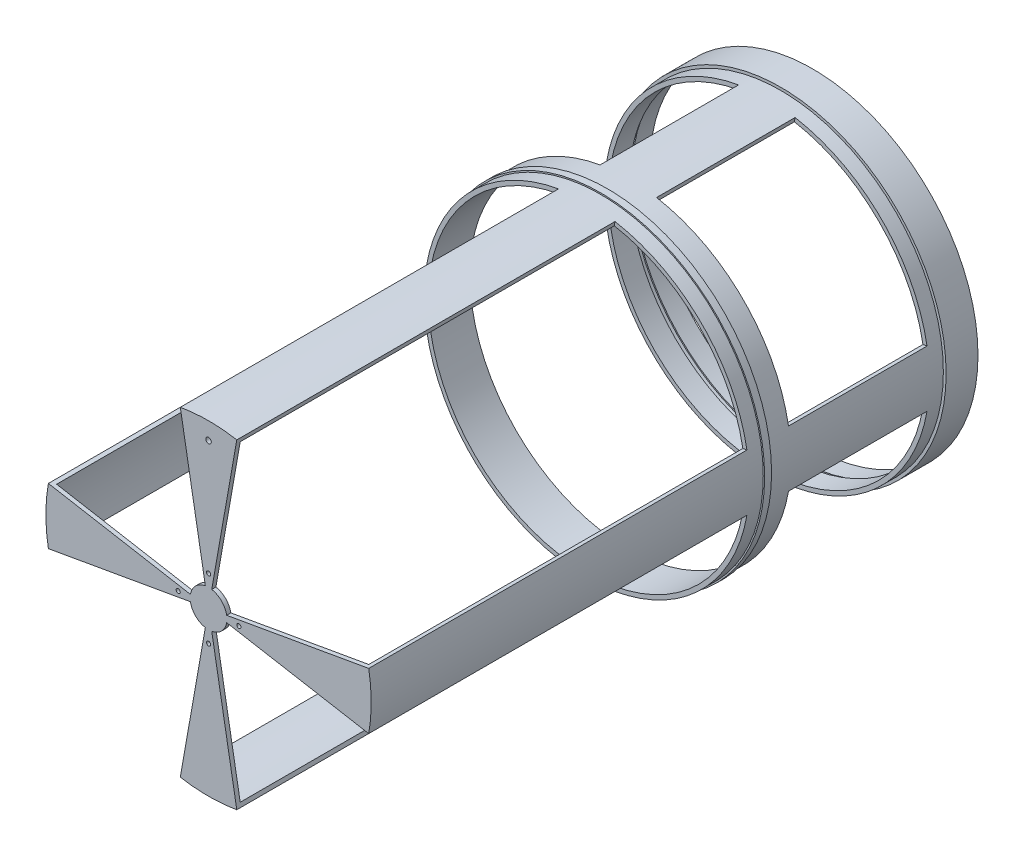
from build123d import *

# Parameters (mm, degrees)
SKETCH1_R       = 119.4
SKETCH1_R_2     = 114.4
EXTRUDE1_DEPTH  = 5
SKETCH2_R       = 119.4
SKETCH2_R_2     = 118.4
EXTRUDE2_DEPTH  = 5
SKETCH3_R       = 119.4
SKETCH3_R_2     = 117.4
EXTRUDE3_DEPTH  = 13
SKETCH4_R       = 117.4
SKETCH4_R_2     = 114.4
EXTRUDE4_DEPTH  = 10
EXTRUDE5_DEPTH  = 100
SKETCH6_R       = 117.4
SKETCH6_R_2     = 114.4
EXTRUDE7_DEPTH  = 15
SKETCH7_R       = 118.4
SKETCH7_R_2     = 114.4
EXTRUDE8_DEPTH  = 5
SKETCH8_R       = 117.4
SKETCH8_R_2     = 114.4
EXTRUDE9_DEPTH  = 10
EXTRUDE10_DEPTH = 270
SKETCH10_R      = 1.5
SKETCH10_R_2    = 2
EXTRUDE11_DEPTH = 3


with BuildPart() as part:
    # Sketch1 → Extrude1 (new body)
    with BuildSketch(Plane.XY):
        Circle(SKETCH1_R)
        Circle(SKETCH1_R_2, mode=Mode.SUBTRACT)
    extrude(amount=-EXTRUDE1_DEPTH)

    # Sketch2 → Extrude2 (add)
    with BuildSketch(Plane(origin=(0, 0, -5), x_dir=(-1, 0, 0), z_dir=(0, 0, -1))):
        Circle(SKETCH2_R)
        Circle(SKETCH2_R_2, mode=Mode.SUBTRACT)
    extrude(amount=EXTRUDE2_DEPTH)

    # Sketch3 → Extrude3 (add)
    with BuildSketch(Plane(origin=(0, 0, -10), x_dir=(-1, 0, 0), z_dir=(0, 0, -1))):
        Circle(SKETCH3_R)
        Circle(SKETCH3_R_2, mode=Mode.SUBTRACT)
    extrude(amount=EXTRUDE3_DEPTH)

    # Sketch4 → Extrude4 (add)
    with BuildSketch(Plane.XY):
        Circle(SKETCH4_R)
        Circle(SKETCH4_R_2, mode=Mode.SUBTRACT)
    extrude(amount=EXTRUDE4_DEPTH)

    # Sketch5 → Extrude5 (add)
    with BuildSketch(Plane.XY.offset(10)):
        with BuildLine():
            Line((20.386296, 115.61643), (19.865352, 112.662007))
            ThreePointArc((19.865352, 112.662007), (0, 114.4), (-19.865352, 112.662007))
            Line((-19.865352, 112.662007), (-20.386296, 115.61643))
            ThreePointArc((-20.386296, 115.61643), (0, 117.4), (20.386296, 115.61643))
        make_face()
        with BuildLine():
            Line((115.61643, 20.386296), (112.662007, 19.865352))
            ThreePointArc((112.662007, 19.865352), (114.4, 0), (112.662007, -19.865352))
            Line((112.662007, -19.865352), (115.61643, -20.386296))
            ThreePointArc((115.61643, -20.386296), (117.4, 0), (115.61643, 20.386296))
        make_face()
        with BuildLine():
            Line((19.865352, -112.662007), (20.386296, -115.61643))
            ThreePointArc((20.386296, -115.61643), (0, -117.4), (-20.386296, -115.61643))
            Line((-20.386296, -115.61643), (-19.865352, -112.662007))
            ThreePointArc((-19.865352, -112.662007), (0, -114.4), (19.865352, -112.662007))
        make_face()
        with BuildLine():
            Line((-112.662007, -19.865352), (-115.61643, -20.386296))
            ThreePointArc((-115.61643, -20.386296), (-117.4, 0), (-115.61643, 20.386296))
            Line((-115.61643, 20.386296), (-112.662007, 19.865352))
            ThreePointArc((-112.662007, 19.865352), (-114.4, 0), (-112.662007, -19.865352))
        make_face()
    extrude(amount=EXTRUDE5_DEPTH)

    # Sketch6 → Extrude7 (add)
    with BuildSketch(Plane.XY.offset(110)):
        Circle(SKETCH6_R)
        Circle(SKETCH6_R_2, mode=Mode.SUBTRACT)
    extrude(amount=EXTRUDE7_DEPTH)

    # Sketch7 → Extrude8 (add)
    with BuildSketch(Plane.XY.offset(125)):
        Circle(SKETCH7_R)
        Circle(SKETCH7_R_2, mode=Mode.SUBTRACT)
    extrude(amount=EXTRUDE8_DEPTH)

    # Sketch8 → Extrude9 (add)
    with BuildSketch(Plane.XY.offset(130)):
        Circle(SKETCH8_R)
        Circle(SKETCH8_R_2, mode=Mode.SUBTRACT)
    extrude(amount=EXTRUDE9_DEPTH)

    # Sketch9 → Extrude10 (add)
    with BuildSketch(Plane.XY.offset(140)):
        with BuildLine():
            Line((-20.386296, 115.61643), (-19.865352, 112.662007))
            ThreePointArc((-19.865352, 112.662007), (0, 114.4), (19.865352, 112.662007))
            Line((19.865352, 112.662007), (20.386296, 115.61643))
            ThreePointArc((20.386296, 115.61643), (0, 117.4), (-20.386296, 115.61643))
        make_face()
        with BuildLine():
            Line((112.662007, 19.865352), (115.61643, 20.386296))
            ThreePointArc((115.61643, 20.386296), (117.4, 0), (115.61643, -20.386296))
            Line((115.61643, -20.386296), (112.662007, -19.865352))
            ThreePointArc((112.662007, -19.865352), (114.4, 0), (112.662007, 19.865352))
        make_face()
        with BuildLine():
            Line((19.865352, -112.662007), (20.386296, -115.61643))
            ThreePointArc((20.386296, -115.61643), (0, -117.4), (-20.386296, -115.61643))
            Line((-20.386296, -115.61643), (-19.865352, -112.662007))
            ThreePointArc((-19.865352, -112.662007), (0, -114.4), (19.865352, -112.662007))
        make_face()
        with BuildLine():
            Line((-112.662007, -19.865352), (-115.61643, -20.386296))
            ThreePointArc((-115.61643, -20.386296), (-117.4, 0), (-115.61643, 20.386296))
            Line((-115.61643, 20.386296), (-112.662007, 19.865352))
            ThreePointArc((-112.662007, 19.865352), (-114.4, 0), (-112.662007, -19.865352))
        make_face()
    extrude(amount=EXTRUDE10_DEPTH)

    # Sketch10 → Extrude11 (add)
    with BuildSketch(Plane.XY.offset(410)):
        with BuildLine():
            Line((13.065229, 2.303752), (115.61643, 20.386296))
            ThreePointArc((115.61643, 20.386296), (117.4, 0), (115.61643, -20.386296))
            Line((115.61643, -20.386296), (13.065229, -2.303752))
            ThreePointArc((13.065229, -2.303752), (9.381031, -9.381031), (2.303752, -13.065229))
            Line((2.303752, -13.065229), (20.386296, -115.61643))
            ThreePointArc((20.386296, -115.61643), (0, -117.4), (-20.386296, -115.61643))
            Line((-20.386296, -115.61643), (-2.303752, -13.065229))
            ThreePointArc((-2.303752, -13.065229), (-9.381031, -9.381031), (-13.065229, -2.303752))
            Line((-13.065229, -2.303752), (-115.61643, -20.386296))
            ThreePointArc((-115.61643, -20.386296), (-117.4, 0), (-115.61643, 20.386296))
            Line((-115.61643, 20.386296), (-13.065229, 2.303752))
            ThreePointArc((-13.065229, 2.303752), (-9.381031, 9.381031), (-2.303752, 13.065229))
            Line((-2.303752, 13.065229), (-20.386296, 115.61643))
            ThreePointArc((-20.386296, 115.61643), (0, 117.4), (20.386296, 115.61643))
            Line((20.386296, 115.61643), (2.303752, 13.065229))
            ThreePointArc((2.303752, 13.065229), (9.381031, 9.381031), (13.065229, 2.303752))
        make_face()
        with Locations((21.92, 0)):
            Circle(SKETCH10_R, mode=Mode.SUBTRACT)
        with Locations((0, -21.92)):
            Circle(SKETCH10_R, mode=Mode.SUBTRACT)
        with Locations((-21.92, 0)):
            Circle(SKETCH10_R, mode=Mode.SUBTRACT)
        with Locations((0, 21.92)):
            Circle(SKETCH10_R, mode=Mode.SUBTRACT)
        with Locations((0, 105.043168)):
            Circle(SKETCH10_R_2, mode=Mode.SUBTRACT)
    extrude(amount=EXTRUDE11_DEPTH)


solid = part.part
